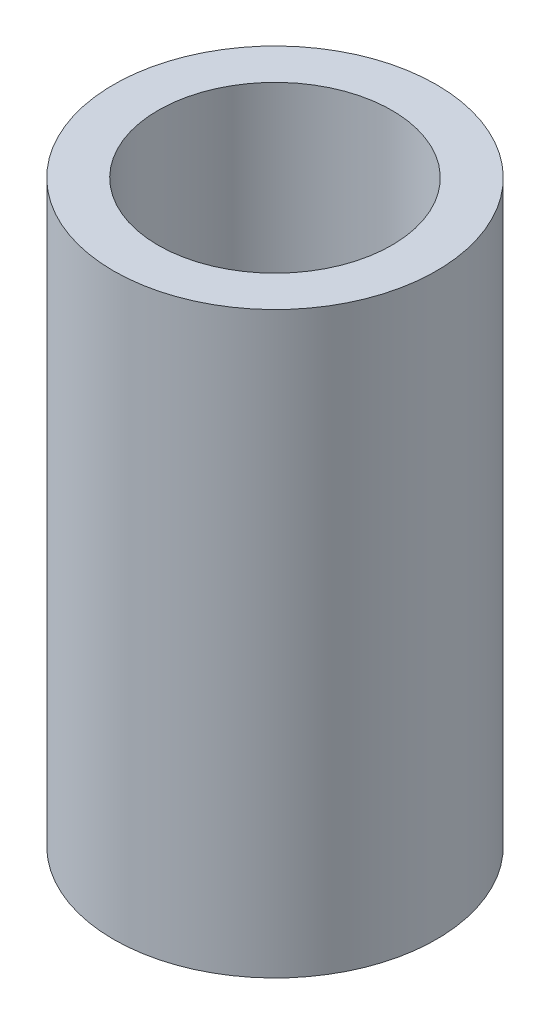
from build123d import *

# Parameters (mm, degrees)
CROQUIS1_R              = 7.25
CROQUIS1_R_2            = 5.25
SALIENTE_EXTRUIR1_DEPTH = 26


with BuildPart() as part:
    # Croquis1 → Saliente-Extruir1 (new body)
    with BuildSketch(Plane(origin=(0, 0, 0), x_dir=(1, 0, 0), z_dir=(0, 1, 0))):
        Circle(CROQUIS1_R)
        Circle(CROQUIS1_R_2, mode=Mode.SUBTRACT)
    extrude(amount=SALIENTE_EXTRUIR1_DEPTH)


solid = part.part
